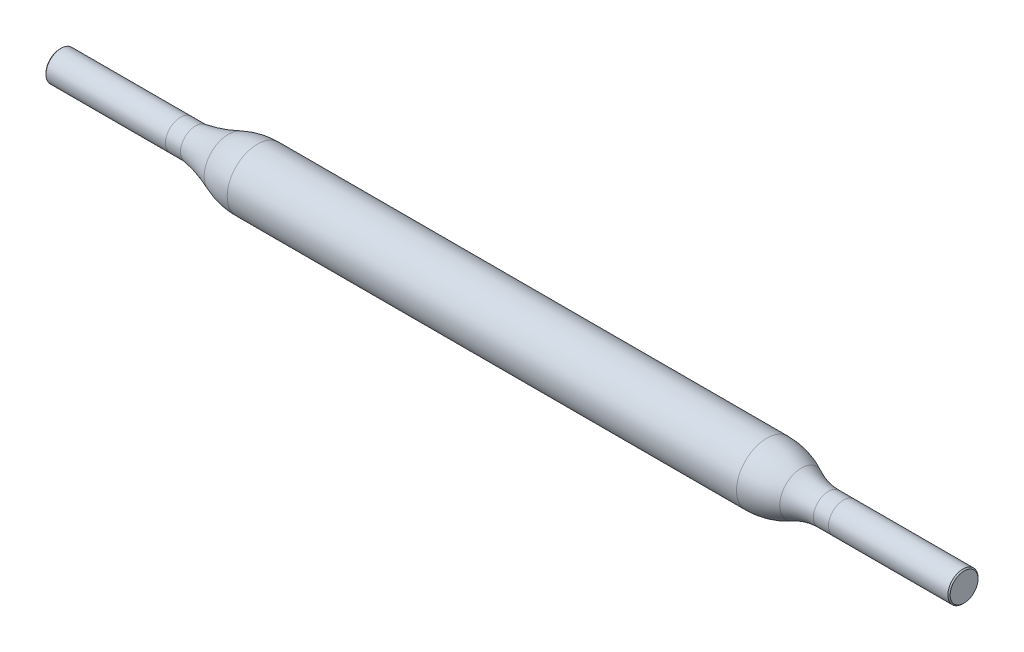
from build123d import *

# Parameters (mm, degrees)
CHAMFER1_SIZE = 0.075


with BuildPart() as part:
    # Sketch1 → Revolve1 (revolve)
    with BuildSketch(Plane.XY):
        with BuildLine():
            Line((-30, 0), (30, 0))
            Line((30, 0), (30, 1))
            Line((30, 1), (21, 1))
            ThreePointArc((21, 1), (20.074719347, 1.111210238), (19.202143132, 1.438506361))
            ThreePointArc((19.202143132, 1.438506361), (18.084836661, 1.857598779), (16.900043811, 2))
            Line((16.900043811, 2), (-16.900043811, 2))
            ThreePointArc((-16.900043811, 2), (-17.874225193, 1.904178895), (-18.811067721, 1.620388254))
            ThreePointArc((-18.811067721, 1.620388254), (-19.887521878, 1.246641972), (-21, 1))
            Line((-21, 1), (-30, 1))
            Line((-30, 1), (-30, 0))
        make_face()
    revolve(axis=Axis((-30, 0, 0), (1, 0, 0)))

    # Chamfer1
    chamfer1_edges = [part.edges().sort_by_distance(p)[0] for p in [
        (30, -1, 0),
        (-30, -1, 0),
    ]]
    chamfer(chamfer1_edges, length=CHAMFER1_SIZE)


solid = part.part
